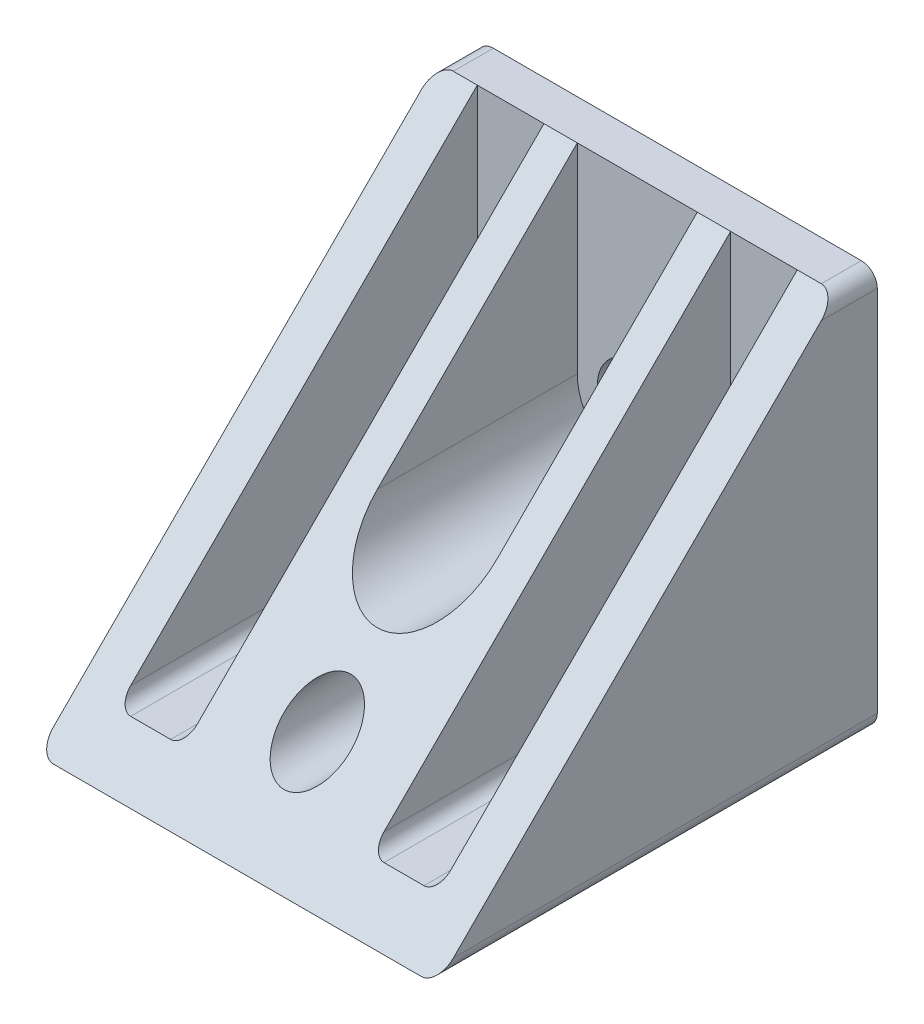
from build123d import *

# Parameters (mm, degrees)
EXTRUDE_1_DEPTH     = 30
SKETCH_2_W          = 5
SKETCH_2_H          = 54
CUT_EXTRUDE_1_DEPTH = 45
FILLET_1_R          = 1
SKETCH_4_R          = 3
CUT_EXTRUDE_2_DEPTH = 45
SKETCH_5_R          = 2.5
CUT_EXTRUDE_3_DEPTH = 92
FILLET_2_R          = 1.2


with BuildPart() as part:
    # 草图1 → 凸台-拉伸1 (new body)
    with BuildSketch(Plane(origin=(0, 0, 0), x_dir=(0, 0, -1), z_dir=(1, 0, 0))):
        Polygon((0, 30), (0, 0), (-33, 0), (-3, 30), align=None)
    extrude(amount=EXTRUDE_1_DEPTH)

    # 草图2 → 切除-拉伸1 (cut)
    with BuildSketch(Plane(origin=(0, 0, 3), x_dir=(-1, 0, 0), z_dir=(0, 0, -1))):
        with BuildLine():
            Line((-19.5, 15), (-19.5, 31.772972214))
            ThreePointArc((-19.5, 31.772972214), (-15, 36.272972214), (-10.5, 31.772972214))
            Line((-10.5, 31.772972214), (-10.5, 15))
            ThreePointArc((-10.5, 15), (-15, 10.5), (-19.5, 15))
        make_face()
        with Locations((-5.5, 30)):
            Rectangle(SKETCH_2_W, SKETCH_2_H)
        with Locations((-24.5, 30)):
            Rectangle(SKETCH_2_W, SKETCH_2_H)
    extrude(amount=-CUT_EXTRUDE_1_DEPTH, mode=Mode.SUBTRACT)

    # 圆角1
    fillet_1_edges = [part.edges().sort_by_distance(p)[0] for p in [
        (27, 3, 16.5),
        (22, 3, 16.5),
        (8, 3, 16.5),
        (3, 3, 16.5),
    ]]
    fillet(fillet_1_edges, radius=FILLET_1_R)

    # 草图4 → 切除-拉伸2 (cut)
    with BuildSketch(Plane.XY.offset(3)):
        with Locations((15, 15)):
            Circle(SKETCH_4_R)
    extrude(amount=-CUT_EXTRUDE_2_DEPTH, mode=Mode.SUBTRACT)

    # 草图5 → 切除-拉伸3 (cut)
    with BuildSketch(Plane.XY):
        with Locations((15, 6)):
            Circle(SKETCH_5_R)
    extrude(amount=CUT_EXTRUDE_3_DEPTH, mode=Mode.SUBTRACT)

    # 圆角2
    fillet_2_edges = [part.edges().sort_by_distance(p)[0] for p in [
        (30, 0, 16.5),
        (30, 30, 1.5),
        (0, 0, 16.5),
        (0, 30, 1.5),
    ]]
    fillet(fillet_2_edges, radius=FILLET_2_R)


solid = part.part
